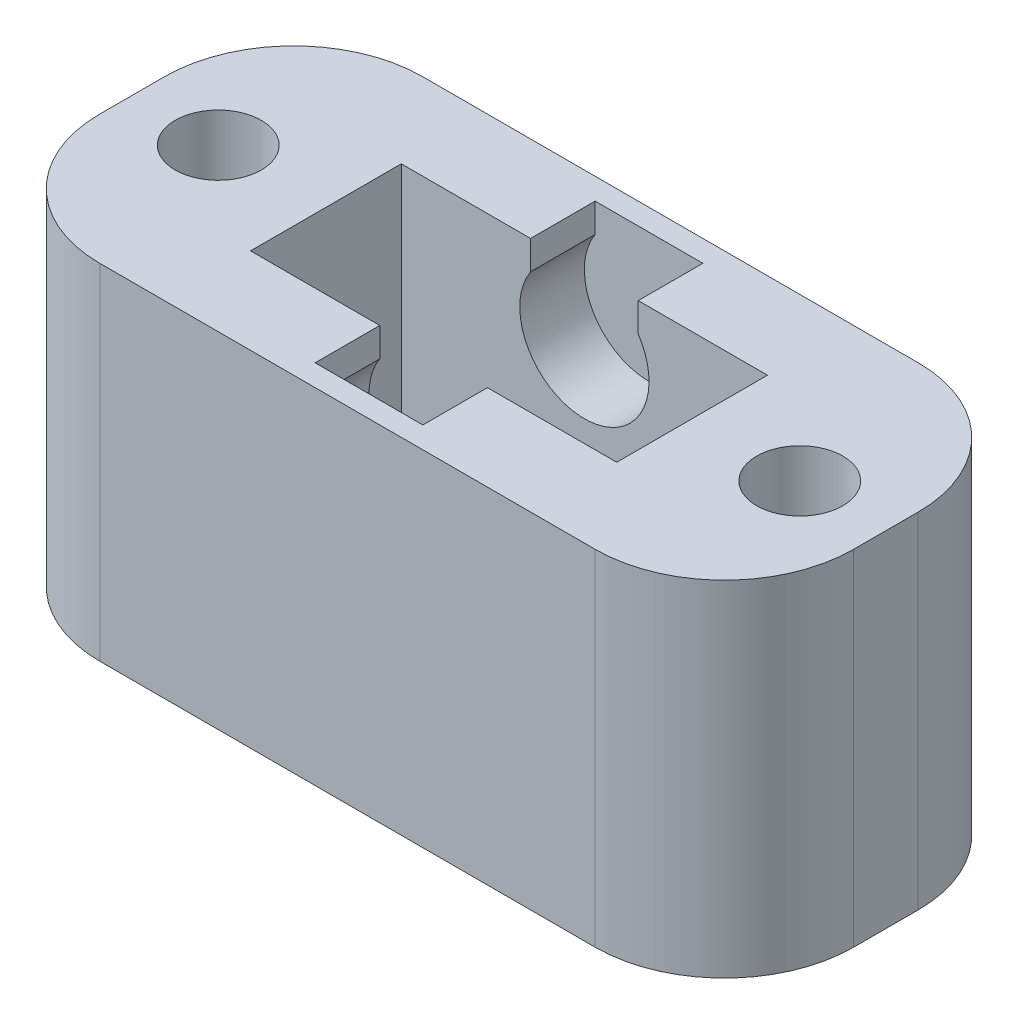
from build123d import *

# Parameters (mm, degrees)
SKETCH1_W           = 17.5
SKETCH1_H           = 7.5
SKETCH1_R           = 1
SKETCH1_W_2         = 8.5
SKETCH1_H_2         = 3.5
BOSS_EXTRUDE1_DEPTH = 8
FILLET1_R           = 3
SKETCH3_R           = 1.5
SKETCH3_W           = 2.5
SKETCH3_H           = 1.5
CUT_EXTRUDE1_DEPTH  = 1.5


with BuildPart() as part:
    # Sketch1 → Boss-Extrude1 (new body)
    with BuildSketch(Plane(origin=(0, 0, 0), x_dir=(1, 0, 0), z_dir=(0, 1, 0))):
        Rectangle(SKETCH1_W, SKETCH1_H)
        with Locations((-6.75, 0)):
            Circle(SKETCH1_R, mode=Mode.SUBTRACT)
        with Locations((6.75, 0)):
            Circle(SKETCH1_R, mode=Mode.SUBTRACT)
        Rectangle(SKETCH1_W_2, SKETCH1_H_2, mode=Mode.SUBTRACT)
    extrude(amount=BOSS_EXTRUDE1_DEPTH)

    # Fillet1
    fillet1_edges = [part.edges().sort_by_distance(p)[0] for p in [
        (8.75, 4, 3.75),
        (-8.75, 4, 3.75),
        (-8.75, 4, -3.75),
        (8.75, 4, -3.75),
    ]]
    fillet(fillet1_edges, radius=FILLET1_R)

    # Sketch3 → Cut-Extrude1 (cut)
    with BuildSketch(Plane(origin=(0, 0, 1.75), x_dir=(-1, 0, 0), z_dir=(0, 0, -1))):
        with Locations((0, 6.5)):
            Circle(SKETCH3_R)
        with Locations((0, 7.25)):
            Rectangle(SKETCH3_W, SKETCH3_H)
    cut_extrude1 = extrude(amount=-CUT_EXTRUDE1_DEPTH, mode=Mode.SUBTRACT)

    # Mirror1: Cut-Extrude1 across plane
    add(cut_extrude1.mirror(Plane.XY), mode=Mode.SUBTRACT)


solid = part.part
